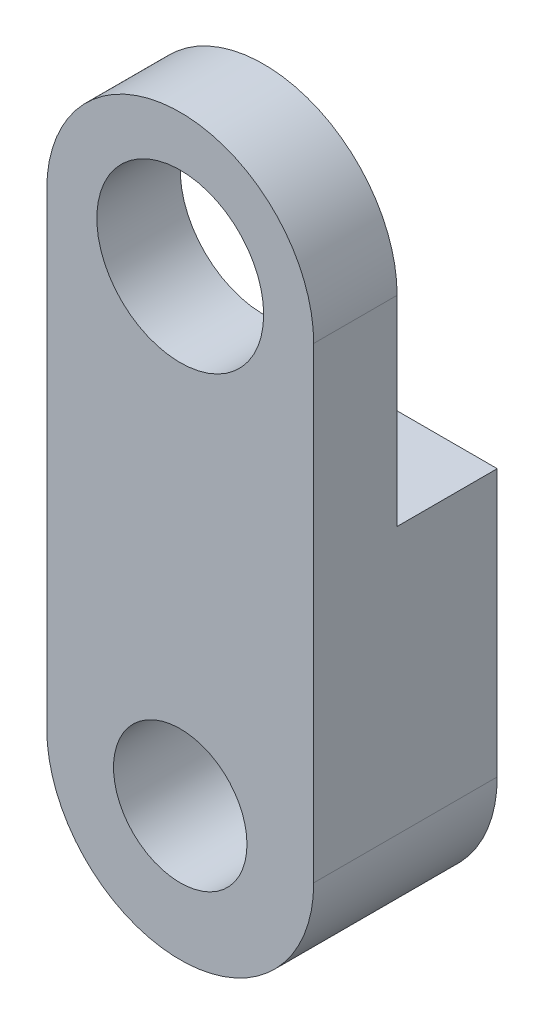
from build123d import *

# Parameters (mm, degrees)
ESQUISSE1_R                  = 2
ESQUISSE1_R_2                = 2.5
BOSS_EXTRU_1_DEPTH           = 5.5
ESQUISSE2_W                  = 3
ESQUISSE2_H                  = 10
ENL_V_MAT_EXTRU_1_DEPTH      = 5
ENL_V_MAT_EXTRU_1_DEPTH_BACK = 5


with BuildPart() as part:
    # Esquisse1 → Boss.-Extru.1 (new body)
    with BuildSketch(Plane.XY):
        with BuildLine():
            Line((-4, -7), (-4, 7))
            ThreePointArc((-4, 7), (0, 11), (4, 7))
            Line((4, 7), (4, -7))
            ThreePointArc((4, -7), (0, -11), (-4, -7))
        make_face()
        with Locations((0, -7)):
            Circle(ESQUISSE1_R, mode=Mode.SUBTRACT)
        with Locations((0, 7)):
            Circle(ESQUISSE1_R_2, mode=Mode.SUBTRACT)
    extrude(amount=BOSS_EXTRU_1_DEPTH)

    # Esquisse2 → Enlèv. mat.-Extru.1 (cut, two sides)
    with BuildSketch(Plane(origin=(0, 0, 0), x_dir=(0, 0, -1), z_dir=(1, 0, 0))) as enl_v_mat_extru_1_sk:
        with Locations((-1.5, 6)):
            Rectangle(ESQUISSE2_W, ESQUISSE2_H)
    extrude(amount=ENL_V_MAT_EXTRU_1_DEPTH, mode=Mode.SUBTRACT)
    extrude(enl_v_mat_extru_1_sk.sketch, amount=-ENL_V_MAT_EXTRU_1_DEPTH_BACK, mode=Mode.SUBTRACT)


solid = part.part
